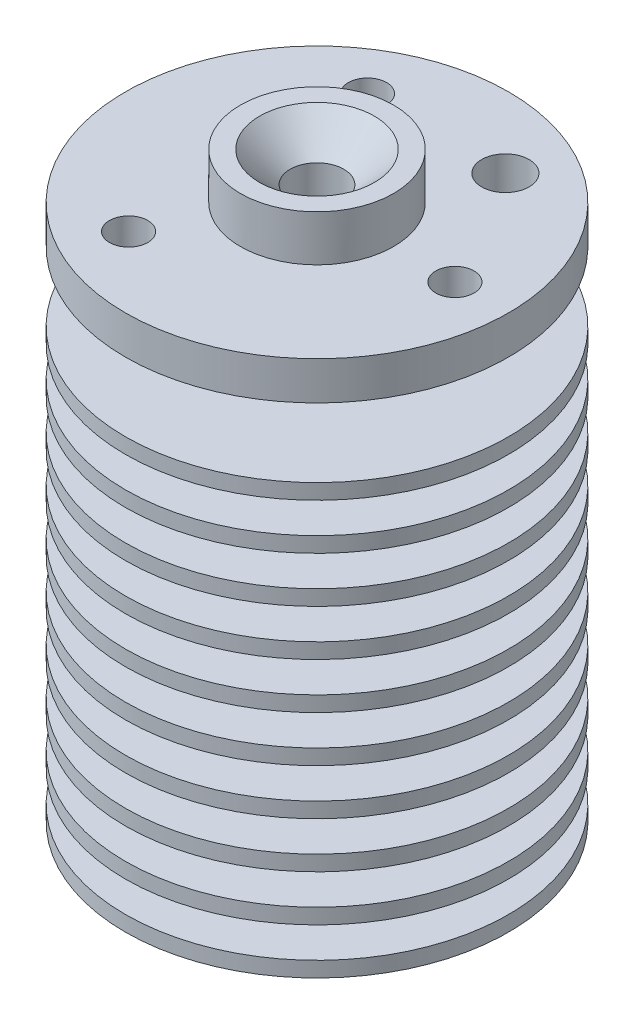
from build123d import *

# Parameters (mm, degrees)
LPATTERN1_COUNT       = 11
LPATTERN1_PITCH       = 3
SKETCH3_R             = 5.000000000000004
BOSS_EXTRUDE1_DEPTH   = 3
SKETCH4_R             = 1.75
CUT_EXTRUDE1_DEPTH    = 43.81938813201328
CHAMFER1_SIZE         = 2
SKETCH5_R             = 1.2499999999999991
SKETCH5_R_2           = 1.2500000000000002
CUT_EXTRUDE2_DEPTH    = 2
SKETCH6_R             = 12.499999999999995
CUT_EXTRUDE3_DEPTH    = 1
CUT_EXTRUDE5_REACH    = 37.686
SKETCH7_R             = 12.499999999999996
SKETCH7_R_2           = 3.4999999999999982
SKETCH8_R             = 4.999999999999997
SKETCH8_R_2           = 3.4999999999999982
BOSS_EXTRUDE2_DEPTH   = 8
BOSS_EXTRUDE3_START   = 0.5
SKETCH9_R             = 12.499999999999996
SKETCH9_R_2           = 1.2499999999999991
SKETCH9_R_3           = 3.499999999999998
SKETCH9_R_4           = 1.2500000000000009
SKETCH9_R_5           = 1.2500000000000002
BOSS_EXTRUDE3_DEPTH   = 0.5
CROQUIS1_R            = 1.550000000000001
CORTAR_EXTRUIR1_DEPTH = 2.5


with BuildPart() as part:
    # Sketch1 → Revolve1 (revolve)
    with BuildSketch(Plane.XY, mode=Mode.PRIVATE) as revolve1_sk:
        Polygon((-2.5, -3.1e-16), (-2.5, 7.999999999999998), (-0.7999999999999999, 7.999999999999998), (-0.8, 36), (-12.5, 36), (-12.499999999999995, 0), align=None)
    revolve(revolve1_sk.sketch.rotate(Axis((0, 0, 0), (0, 1, 0)), 270), axis=Axis((0, 0, 0), (0, 1, 0)))

    # Sketch2 → Cut-Revolve1 (revolve, cut)
    with BuildSketch(Plane(origin=(0, 0, 0), x_dir=(0, 0, -1), z_dir=(1, 0, 0))):
        Polygon((12.499999999999996, 33.99999999999999), (3.4999999999999973, 33.99999999999999), (3.499999999999998, 31.999999999999993), (12.499999999999996, 31.999999999999993), align=None)
    cut_revolve1 = revolve(axis=Axis((0, 36, 0), (0, -1, 0)), mode=Mode.SUBTRACT)

    # LPattern1: Cut-Revolve1 ×11
    with Locations(*[(0, -i * LPATTERN1_PITCH, 0) for i in range(1, LPATTERN1_COUNT)]):
        add(cut_revolve1, mode=Mode.SUBTRACT)

    # Sketch3 → Boss-Extrude1 (add)
    with BuildSketch(Plane(origin=(0, 36, 0), x_dir=(1, 0, 0), z_dir=(0, 1, 0))):
        with Locations(Location((0, 0, 0), (0, 0, 90))):
            Circle(SKETCH3_R)
    extrude(amount=BOSS_EXTRUDE1_DEPTH)

    # Sketch4 → Cut-Extrude1 (cut, through all)
    with BuildSketch(Plane(origin=(0, 39, 0), x_dir=(1, 0, 0), z_dir=(0, 1, 0))):
        with Locations(Location((0, 0, 0), (0, 0, 270))):
            Circle(SKETCH4_R)
    extrude(amount=-CUT_EXTRUDE1_DEPTH, mode=Mode.SUBTRACT)

    # Chamfer1
    chamfer1_edges = [part.edges().sort_by_distance(p)[0] for p in [
        (5.4e-16, 39, -1.75),
    ]]
    chamfer(chamfer1_edges, length=CHAMFER1_SIZE)

    # Sketch5 → Cut-Extrude2 (cut)
    with BuildSketch(Plane(origin=(0, 36, 0), x_dir=(1, 0, 0), z_dir=(0, 1, 0))):
        with Locations(Location((9, -9.8e-16, 0), (0, 0, 270))):
            Circle(SKETCH5_R)
        with Locations(Location((-4.499999999999999, -7.794228634059948, 0), (0, 0, 270))):
            Circle(SKETCH5_R_2)
        with Locations(Location((-4.5000000000000036, 7.794228634059946, 0), (0, 0, 270))):
            Circle(SKETCH5_R_2)
    extrude(amount=-CUT_EXTRUDE2_DEPTH, mode=Mode.SUBTRACT)

    # Sketch6 → Cut-Extrude3 (cut)
    with BuildSketch(Plane.XZ):
        with Locations(Location((0, 0, 0), (0, 0, 270))):
            Circle(SKETCH6_R)
    extrude(amount=-CUT_EXTRUDE3_DEPTH, mode=Mode.SUBTRACT)

    # Sketch7 → Cut-Extrude5 (cut, up to next)
    with BuildSketch(Plane(origin=(0, 31.999999999999993, 0), x_dir=(1, 0, 0), z_dir=(0, 1, 0)), mode=Mode.PRIVATE) as cut_extrude5_sk1:
        with Locations(Location((0, 0, 0), (0, 0, 90))):
            Circle(SKETCH7_R)
        with Locations(Location((0, 0, 0), (0, 0, 270))):
            Circle(SKETCH7_R_2, mode=Mode.SUBTRACT)
    cut_extrude5_tool1 = extrude(cut_extrude5_sk1.sketch, amount=-CUT_EXTRUDE5_REACH, mode=Mode.PRIVATE) & part.part
    add(cut_extrude5_tool1.solids().sort_by_distance((0, 32, 12.146447))[0], mode=Mode.SUBTRACT)

    # Sketch8 → Boss-Extrude2 (add)
    with BuildSketch(Plane(origin=(0, 1.999999999999995, 0), x_dir=(1, 0, 0), z_dir=(0, 1, 0))):
        with Locations(Location((0, 0, 0), (0, 0, 90))):
            Circle(SKETCH8_R)
        with Locations(Location((0, 0, 0), (0, 0, 270))):
            Circle(SKETCH8_R_2, mode=Mode.SUBTRACT)
    extrude(amount=BOSS_EXTRUDE2_DEPTH)

    # Sketch9 → Boss-Extrude3 (add)
    with BuildSketch(Plane.XZ.offset(-33.99999999999999).offset(BOSS_EXTRUDE3_START)):
        with Locations(Location((0, 0, 0), (0, 0, 270))):
            Circle(SKETCH9_R)
        with Locations(Location((9, 9.8e-16, 0), (0, 0, 90))):
            Circle(SKETCH9_R_2, mode=Mode.SUBTRACT)
        with Locations(Location((0, 0, 0), (0, 0, 90))):
            Circle(SKETCH9_R_3, mode=Mode.SUBTRACT)
        with Locations(Location((-4.499999999999999, 7.794228634059948, 0), (0, 0, 90))):
            Circle(SKETCH9_R_4, mode=Mode.SUBTRACT)
        with Locations(Location((-4.5000000000000036, -7.794228634059946, 0), (0, 0, 90))):
            Circle(SKETCH9_R_5, mode=Mode.SUBTRACT)
    extrude(amount=-BOSS_EXTRUDE3_DEPTH)

    # Croquis1 → Cortar-Extruir1 (cut)
    with BuildSketch(Plane(origin=(0, 36, 0), x_dir=(1, 0, 0), z_dir=(0, 1, 0))):
        with Locations(Location((4.49999999999998, 7.7942286340599605, 0), (0, 0, 270))):
            Circle(CROQUIS1_R)
    extrude(amount=-CORTAR_EXTRUIR1_DEPTH, mode=Mode.SUBTRACT)


solid = part.part
